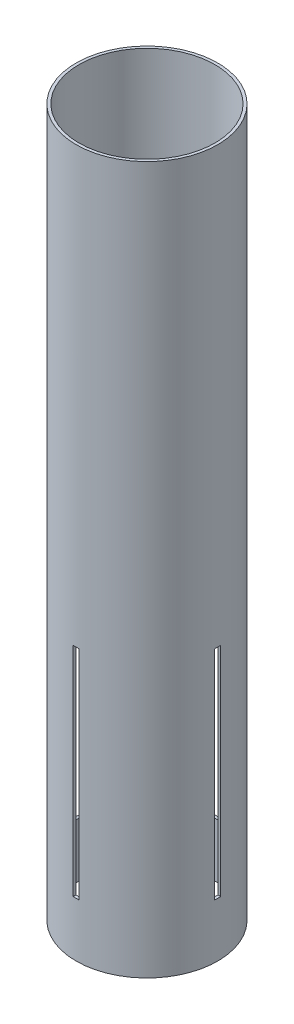
from build123d import *

# Parameters (mm, degrees)
SKETCH1_R           = 39.6748
SKETCH1_R_2         = 38.1
BOSS_EXTRUDE1_DEPTH = 198.12
SKETCH2_W           = 3.3655
SKETCH2_H           = 121.92
CUT_EXTRUDE1_DEPTH  = 40.6748
CIRPATTERN2_COUNT   = 2
CIRPATTERN2_ANGLE   = 90


with BuildPart() as part:
    # Sketch1 → Boss-Extrude1 (new body, symmetric)
    with BuildSketch(Plane(origin=(0, 0, 0), x_dir=(1, 0, 0), z_dir=(0, 1, 0))):
        Circle(SKETCH1_R)
        Circle(SKETCH1_R_2, mode=Mode.SUBTRACT)
    extrude(amount=BOSS_EXTRUDE1_DEPTH, both=True)

    # Sketch2 → Cut-Extrude1 (cut, symmetric)
    with BuildSketch(Plane(origin=(0, 0, 0), x_dir=(0, 0, -1), z_dir=(1, 0, 0))):
        with Locations((0, -106.68)):
            Rectangle(SKETCH2_W, SKETCH2_H)
    cut_extrude1 = extrude(amount=CUT_EXTRUDE1_DEPTH, both=True, mode=Mode.SUBTRACT)

    # CirPattern2: Cut-Extrude1 ×2 about axis
    cirpattern2_axis = Axis((0, 198.12, 0), (0, -1, 0))
    for i in range(1, CIRPATTERN2_COUNT):
        add(cut_extrude1.rotate(cirpattern2_axis, i * CIRPATTERN2_ANGLE / (CIRPATTERN2_COUNT - 1)), mode=Mode.SUBTRACT)


solid = part.part
